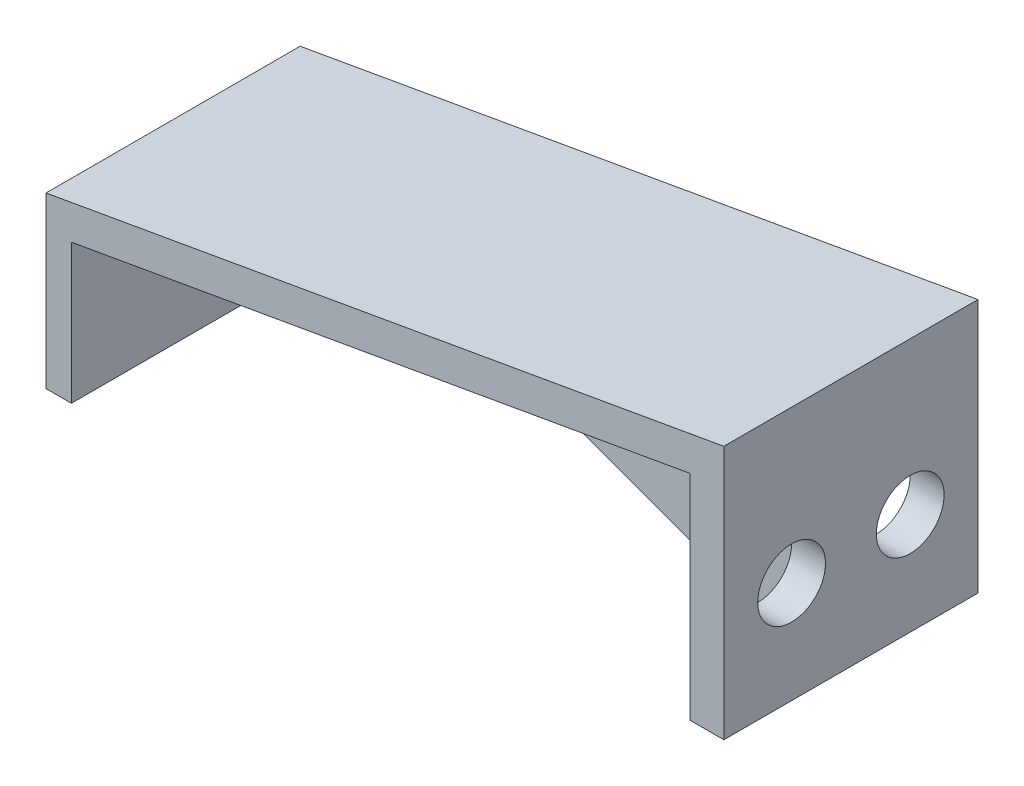
from build123d import *

# Parameters (mm, degrees)
BOSS_EXTRUDE1_DEPTH = 15
BOSS_EXTRUDE2_DEPTH = 0.75
SKETCH6_R           = 2
CUT_EXTRUDE1_DEPTH  = 2
SKETCH7_R           = 2
CUT_EXTRUDE2_DEPTH  = 1.5


with BuildPart() as part:
    # Sketch1 → Boss-Extrude1 (new body)
    with BuildSketch(Plane.XY):
        Polygon((0, 0), (0, 10), (40, 17.053079228), (40, 2.053079228), (38, 2.053079228), (38, 14.669572043), (1.5, 8.233637247), (1.5, 0), align=None)
    extrude(amount=BOSS_EXTRUDE1_DEPTH)

    # Sketch5 → Boss-Extrude2 (add, symmetric)
    with BuildSketch(Plane(origin=(0, 0, 7.5), x_dir=(-1, 0, 0), z_dir=(0, 0, -1))):
        Polygon((-38, 14.669572043), (-38, 2.053079228), (-14.648976776, 10.552156622), align=None)
    extrude(amount=BOSS_EXTRUDE2_DEPTH, both=True)

    # Sketch6 → Cut-Extrude1 (cut)
    with BuildSketch(Plane(origin=(40, 0, 0), x_dir=(0, 0, -1), z_dir=(1, 0, 0))):
        with Locations((-4, 8.069303899)):
            Circle(SKETCH6_R)
        with Locations((-11, 8.069303899)):
            Circle(SKETCH6_R)
    extrude(amount=-CUT_EXTRUDE1_DEPTH, mode=Mode.SUBTRACT)

    # Sketch7 → Cut-Extrude2 (cut)
    with BuildSketch(Plane.ZY):
        with Locations((7.5, 5)):
            Circle(SKETCH7_R)
    extrude(amount=-CUT_EXTRUDE2_DEPTH, mode=Mode.SUBTRACT)


solid = part.part
